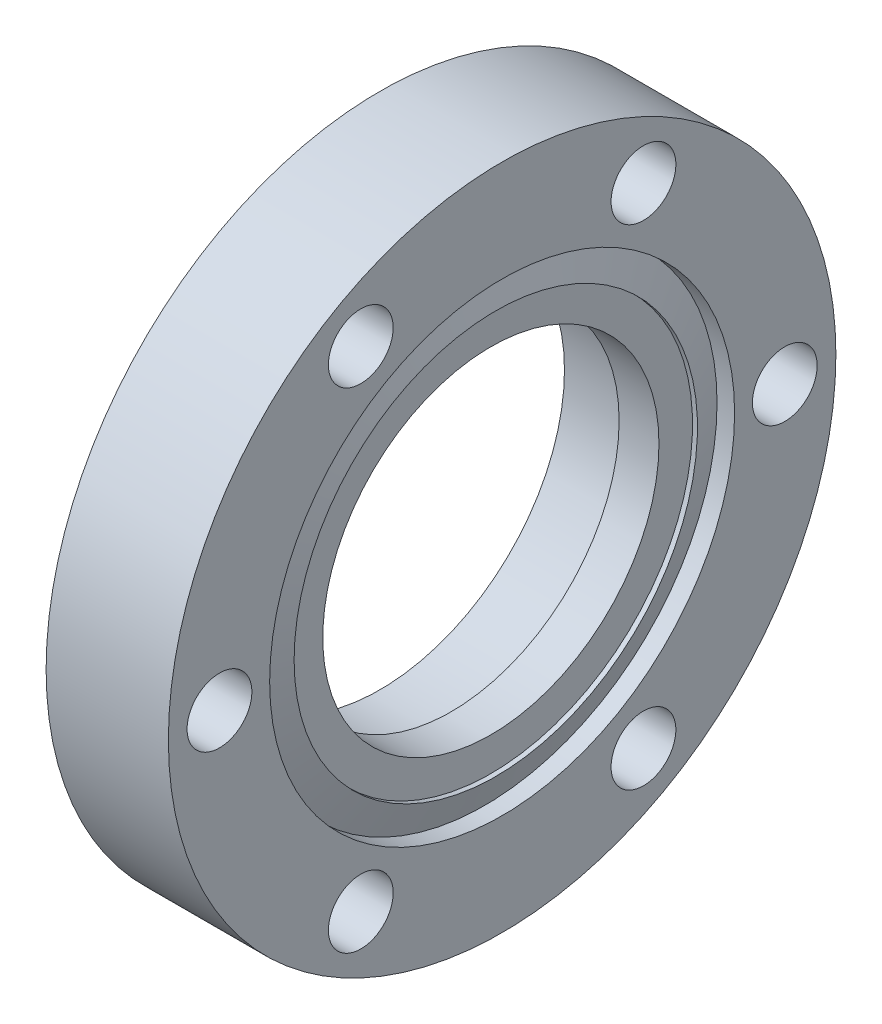
from build123d import *

# Parameters (mm, degrees)
F_1_4_CLEARANCE_HOLE1_D     = 6.731
F_1_4_CLEARANCE_HOLE1_DEPTH = 12.7


with BuildPart() as part:
    # Sketch1 → Revolve1 (revolve)
    with BuildSketch(Plane(origin=(0, 0, 0), x_dir=(-1, 0, 0), z_dir=(0, 0, -1))):
        Polygon((-5.18, 20.95), (-5.18, 0), (6.35, 0), (6.35, 34.671), (-6.35, 34.671), (-6.35, 24.15), (-4.525295248, 24.15), (-5.690000002, 20.95), align=None)
    revolve(axis=Axis((6.35, 0, 0), (-1, 0, 0)))

    # Sketch2 → 1-3/8-6 Tapped Hole1 (revolve, cut)
    with BuildSketch(Plane(origin=(5.18, 0, 0), x_dir=(0, 0, -1), z_dir=(0, 1, 0))):
        Polygon((0, 0), (0, 11.53), (19.177, 11.53), (19.177, 4.1386), (17.4625, 4.1386), (17.4625, 0), align=None)
    revolve(axis=Axis((11.53, 0, 0), (-1, 0, 0)), mode=Mode.SUBTRACT)

    # 1/4 Clearance Hole1
    with Locations(Plane.ZY.offset(6.35)):
        with Locations((14.6812, -25.428584316), (29.3624, 0), (14.6812, 25.428584316), (-14.6812, 25.428584316), (-14.6812, -25.428584316), (-29.3624, 0)):
            Hole(F_1_4_CLEARANCE_HOLE1_D / 2, depth=F_1_4_CLEARANCE_HOLE1_DEPTH)


solid = part.part
